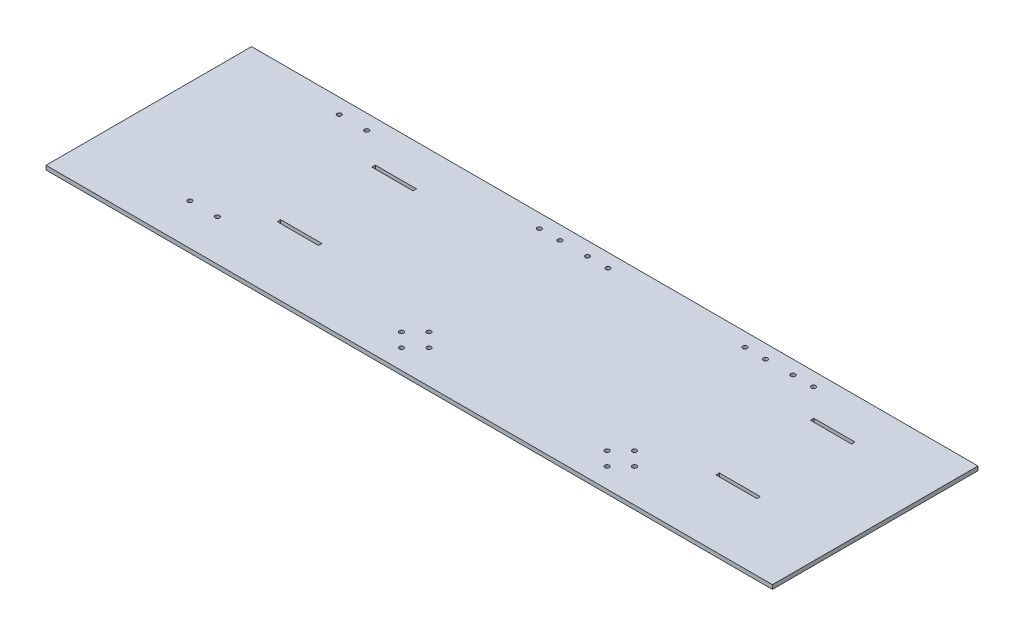
from build123d import *

# Parameters (mm, degrees)
SKETCH_1_R      = 1.6
SKETCH_1_W      = 30
SKETCH_1_H      = 2.5
EXTRUDE_1_DEPTH = 3


with BuildPart() as part:
    # 草图1 → 凸台-拉伸1 (new body)
    with BuildSketch(Plane(origin=(0, 0, 0), x_dir=(1, 0, 0), z_dir=(0, 1, 0))):
        Polygon((-223.132505708, 96.791149389), (246.867494292, 96.791149389), (246.867494292, -53.208850611), (-223.132505708, -53.208850611), (-283.132505708, -53.208850611), (-283.132505708, 96.791149389), align=None)
        with Locations((-208.132505708, -23.208850611)):
            Circle(SKETCH_1_R, mode=Mode.SUBTRACT)
        with Locations((-188.132505708, -23.208850611)):
            Circle(SKETCH_1_R, mode=Mode.SUBTRACT)
        with Locations((-208.132505708, 85.791149389)):
            Circle(SKETCH_1_R, mode=Mode.SUBTRACT)
        with Locations((-188.132505708, 85.791149389)):
            Circle(SKETCH_1_R, mode=Mode.SUBTRACT)
        with Locations((-48.132505708, -28.833850611)):
            Circle(SKETCH_1_R, mode=Mode.SUBTRACT)
        with Locations((-38.132505708, -38.833850611)):
            Circle(SKETCH_1_R, mode=Mode.SUBTRACT)
        with Locations((-28.132505708, -28.833850611)):
            Circle(SKETCH_1_R, mode=Mode.SUBTRACT)
        with Locations((-38.132505708, -18.833850611)):
            Circle(SKETCH_1_R, mode=Mode.SUBTRACT)
        with Locations((101.867494292, -28.833850611)):
            Circle(SKETCH_1_R, mode=Mode.SUBTRACT)
        with Locations((111.867494292, -18.833850611)):
            Circle(SKETCH_1_R, mode=Mode.SUBTRACT)
        with Locations((121.867494292, -28.833850611)):
            Circle(SKETCH_1_R, mode=Mode.SUBTRACT)
        with Locations((111.867494292, -38.833850611)):
            Circle(SKETCH_1_R, mode=Mode.SUBTRACT)
        with Locations((-63.132505708, 86.791149389)):
            Circle(SKETCH_1_R, mode=Mode.SUBTRACT)
        with Locations((-48.132505708, 86.791149389)):
            Circle(SKETCH_1_R, mode=Mode.SUBTRACT)
        with Locations((-28.132505708, 86.791149389)):
            Circle(SKETCH_1_R, mode=Mode.SUBTRACT)
        with Locations((-13.132505708, 86.791149389)):
            Circle(SKETCH_1_R, mode=Mode.SUBTRACT)
        with Locations((86.867494292, 86.791149389)):
            Circle(SKETCH_1_R, mode=Mode.SUBTRACT)
        with Locations((101.867494292, 86.791149389)):
            Circle(SKETCH_1_R, mode=Mode.SUBTRACT)
        with Locations((136.867494292, 86.791149389)):
            Circle(SKETCH_1_R, mode=Mode.SUBTRACT)
        with Locations((121.867494292, 86.791149389)):
            Circle(SKETCH_1_R, mode=Mode.SUBTRACT)
        with Locations((-148.132505708, -3.208850611)):
            Rectangle(SKETCH_1_W, SKETCH_1_H, mode=Mode.SUBTRACT)
        with Locations((171.867494292, -3.208850611)):
            Rectangle(SKETCH_1_W, SKETCH_1_H, mode=Mode.SUBTRACT)
        with Locations((171.867494292, 65.791149389)):
            Rectangle(SKETCH_1_W, SKETCH_1_H, mode=Mode.SUBTRACT)
        with Locations((-148.132505708, 65.791149389)):
            Rectangle(SKETCH_1_W, SKETCH_1_H, mode=Mode.SUBTRACT)
    extrude(amount=EXTRUDE_1_DEPTH)


solid = part.part
